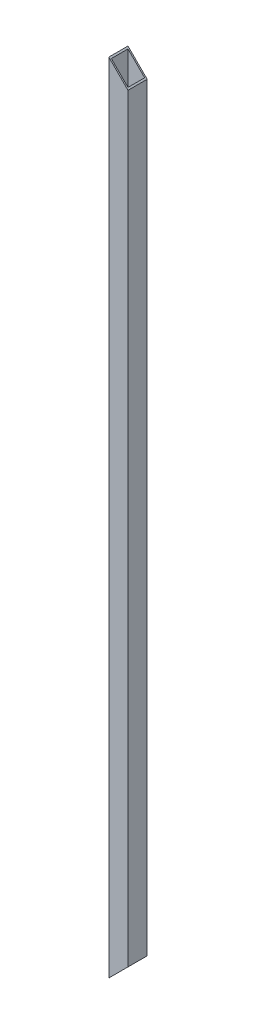
from build123d import *

# Parameters (mm, degrees)
SALIENTE_EXTRUIR1_DEPTH = 2.5
SALIENTE_EXTRUIR2_DEPTH = 33
SALIENTE_EXTRUIR3_DEPTH = 33
SALIENTE_EXTRUIR4_DEPTH = 2.5


with BuildPart() as part:
    # Croquis1 → Saliente-Extruir1 (new body)
    with BuildSketch(Plane.XY.offset(19)):
        Polygon((19, 1542), (-19, 1580), (-19, 0), (19, 38), align=None)
    extrude(amount=-SALIENTE_EXTRUIR1_DEPTH)

    # Croquis2 → Saliente-Extruir2 (add)
    with BuildSketch(Plane(origin=(0, 0, 16.5), x_dir=(-1, 0, 0), z_dir=(0, 0, -1))):
        Polygon((-16.5, 1544.5), (-16.5, 35.5), (-19, 38), (-19, 1542), align=None)
    extrude(amount=SALIENTE_EXTRUIR2_DEPTH)

    # Croquis3 → Saliente-Extruir3 (add)
    with BuildSketch(Plane(origin=(0, 0, 16.5), x_dir=(-1, 0, 0), z_dir=(0, 0, -1))):
        Polygon((16.5, 2.5), (16.5, 1577.5), (19, 1580), (19, 0), align=None)
    extrude(amount=SALIENTE_EXTRUIR3_DEPTH)

    # Croquis4 → Saliente-Extruir4 (add)
    with BuildSketch(Plane(origin=(0, 0, -16.5), x_dir=(-1, 0, 0), z_dir=(0, 0, -1))):
        Polygon((-19, 1542), (19, 1580), (19, 0), (-19, 38), align=None)
    extrude(amount=SALIENTE_EXTRUIR4_DEPTH)


solid = part.part
